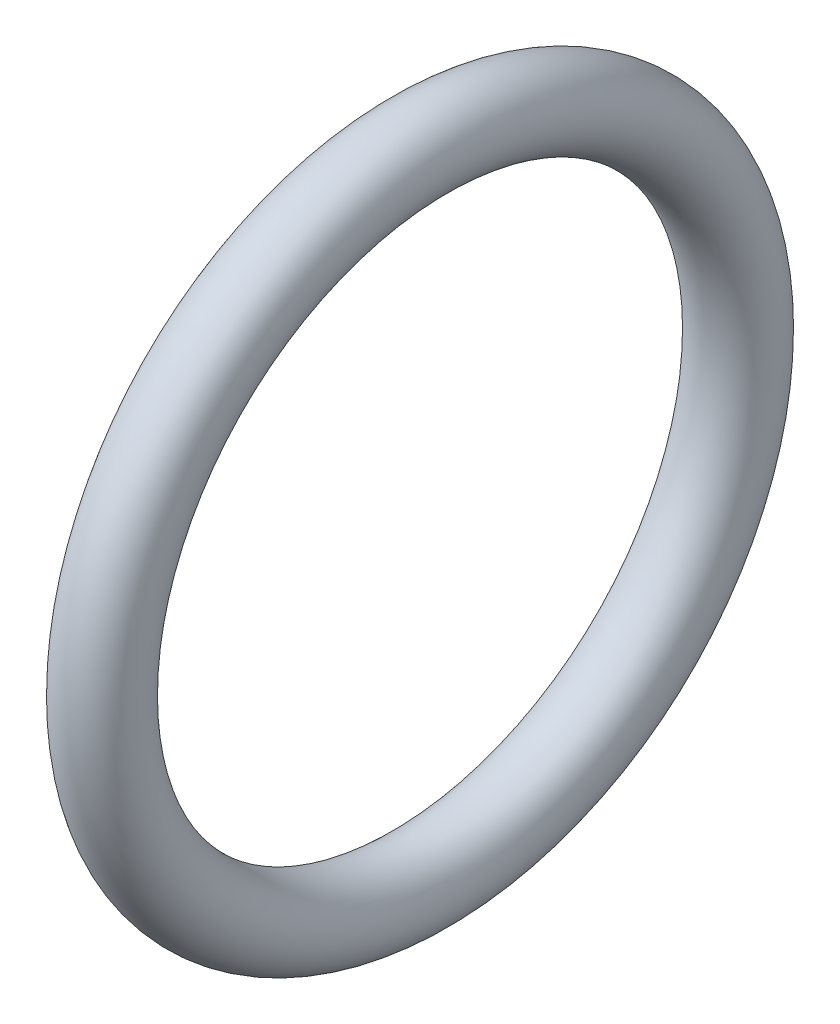
from build123d import *

# Parameters (mm, degrees)
ESQUISSE1_R = 1


with BuildPart() as part:
    # Esquisse1 → Révolution1 (revolve)
    with BuildSketch(Plane.XY, mode=Mode.PRIVATE) as r_volution1_sk:
        with Locations((-0.864124, 8.1)):
            Circle(ESQUISSE1_R)
    revolve(r_volution1_sk.sketch.rotate(Axis((-44.93443299, 0, 0), (1, 0, 0)), 90), axis=Axis((-44.93443299, 0, 0), (1, 0, 0)))  # turned: the seam where the file's is


solid = part.part
